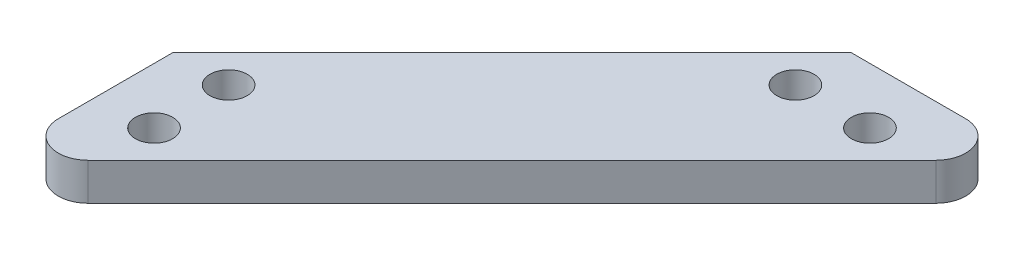
from build123d import *

# Parameters (mm, degrees)
SKETCH1_R           = 1.5875
BOSS_EXTRUDE1_DEPTH = 3.175


with BuildPart() as part:
    # Sketch1 → Boss-Extrude1 (new body)
    with BuildSketch(Plane(origin=(0, 0, 0), x_dir=(1, 0, 0), z_dir=(0, 1, 0))):
        with BuildLine():
            Line((-14.452594388, -14.452594388), (14.452594388, 14.452594388))
            Line((14.452594388, 14.452594388), (24.19549194, 14.452594388))
            ThreePointArc((24.19549194, 14.452594388), (26.542145952, 12.884610306), (25.991543164, 10.116543164))
            Line((25.991543164, 10.116543164), (-10.116543164, -25.991543164))
            ThreePointArc((-10.116543164, -25.991543164), (-12.884610306, -26.542145952), (-14.452594388, -24.19549194))
            Line((-14.452594388, -24.19549194), (-14.452594388, -14.452594388))
        make_face()
        with Locations((-9.690094388, -14.452594388)):
            Circle(SKETCH1_R, mode=Mode.SUBTRACT)
        with Locations((-9.690094388, -20.802594388)):
            Circle(SKETCH1_R, mode=Mode.SUBTRACT)
        with Locations((20.802594388, 9.690094388)):
            Circle(SKETCH1_R, mode=Mode.SUBTRACT)
        with Locations((14.452594388, 9.690094388)):
            Circle(SKETCH1_R, mode=Mode.SUBTRACT)
    extrude(amount=BOSS_EXTRUDE1_DEPTH)


solid = part.part
